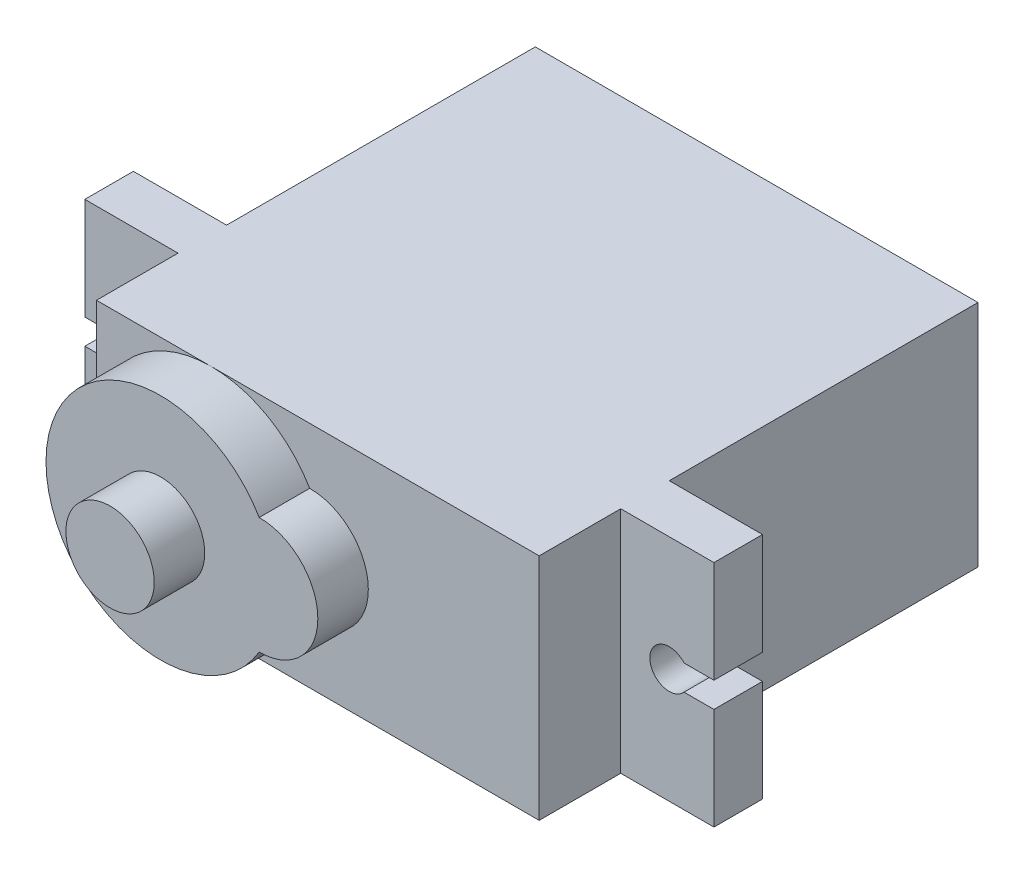
from build123d import *

# Parameters (mm, degrees)
SKETCH_1_W      = 22.8
SKETCH_1_H      = 11.8
EXTRUDE_1_DEPTH = 22.6
SKETCH_2_R      = 5.9
EXTRUDE_2_DEPTH = 2.6
SKETCH_3_R      = 2.275
EXTRUDE_3_DEPTH = 2.6
EXTRUDE_4_DEPTH = 2.6
EXTRUDE_5_DEPTH = 2.5
SKETCH_6_W      = 1.6
SKETCH_6_H      = 4
EXTRUDE_6_DEPTH = 1.5
FILLET_1_R      = 0.4


with BuildPart() as part:
    # Эскиз1 → Бобышка-Вытянуть1 (new body)
    with BuildSketch(Plane.XY):
        Rectangle(SKETCH_1_W, SKETCH_1_H)
    extrude(amount=EXTRUDE_1_DEPTH)

    # Эскиз2 → Бобышка-Вытянуть2 (add)
    with BuildSketch(Plane.XY.offset(22.6)):
        with Locations((-5.5, 0)):
            Circle(SKETCH_2_R)
    extrude(amount=EXTRUDE_2_DEPTH)

    # Эскиз3 → Бобышка-Вытянуть3 (add)
    with BuildSketch(Plane.XY.offset(25.2)):
        with Locations((-5.5, 0)):
            Circle(SKETCH_3_R)
    extrude(amount=EXTRUDE_3_DEPTH)

    # Эскиз4 → Бобышка-Вытянуть4 (add)
    with BuildSketch(Plane.XY.offset(22.6)):
        with BuildLine():
            ThreePointArc((-0.419607843, 2.999935921), (-3.4, 0), (-0.419607843, -2.999935921))
            ThreePointArc((-0.419607843, -2.999935921), (0.4, 0), (-0.419607843, 2.999935921))
        make_face()
        with BuildLine():
            ThreePointArc((-0.419607843, 2.999935921), (0.4, 0), (-0.419607843, -2.999935921))
            ThreePointArc((-0.419607843, -2.999935921), (1.714376559, -2.128241472), (2.6, 0))
            ThreePointArc((2.6, 0), (1.714376559, 2.128241472), (-0.419607843, 2.999935921))
        make_face()
    extrude(amount=EXTRUDE_4_DEPTH)

    # Эскиз5 → Бобышка-Вытянуть5 (add)
    with BuildSketch(Plane(origin=(0, 0, 15.9), x_dir=(-1, 0, 0), z_dir=(0, 0, -1))):
        with BuildLine():
            Line((16.2, 5.9), (-16.2, 5.9))
            Line((-16.2, 5.9), (-16.2, 0.65))
            Line((-16.2, 0.65), (-14.659934208, 0.65))
            ThreePointArc((-14.659934208, 0.65), (-12.9, 0), (-14.659934208, -0.65))
            Line((-14.659934208, -0.65), (-16.2, -0.65))
            Line((-16.2, -0.65), (-16.2, -5.9))
            Line((-16.2, -5.9), (16.2, -5.9))
            Line((16.2, -5.9), (16.2, -0.65))
            Line((16.2, -0.65), (14.659934208, -0.65))
            ThreePointArc((14.659934208, -0.65), (12.9, 0), (14.659934208, 0.65))
            Line((14.659934208, 0.65), (16.2, 0.65))
            Line((16.2, 0.65), (16.2, 5.9))
        make_face()
    extrude(amount=-EXTRUDE_5_DEPTH)

    # Эскиз6 → Бобышка-Вытянуть6 (add)
    with BuildSketch(Plane.ZY.offset(11.4)):
        with Locations((5.3, 0)):
            Rectangle(SKETCH_6_W, SKETCH_6_H)
    extrude(amount=EXTRUDE_6_DEPTH)

    # Скругление1
    fillet_1_edges = [part.edges().sort_by_distance(p)[0] for p in [
        (-12.15, -2, 6.1),
        (-12.15, 2, 6.1),
        (-12.15, 2, 4.5),
        (-12.15, -2, 4.5),
        (-12.9, 0, 6.1),
        (-12.9, 2, 5.3),
        (-12.9, 0, 4.5),
        (-12.9, -2, 5.3),
    ]]
    fillet(fillet_1_edges, radius=FILLET_1_R)


solid = part.part
